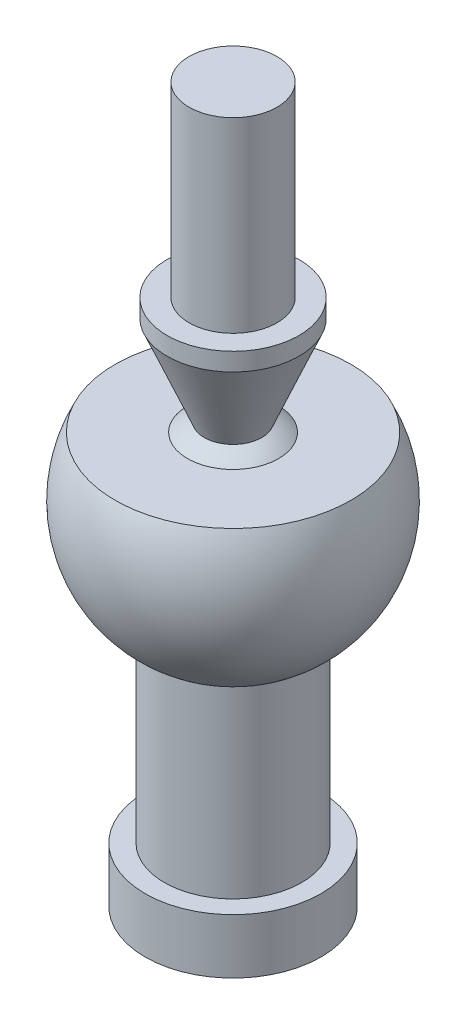
from build123d import *


with BuildPart() as part:
    # 草图1 → 旋转1 (revolve)
    with BuildSketch(Plane.XY):
        with BuildLine():
            Line((0, 12.038127602), (4, 9.728726525))
            Line((4, 9.728726525), (4, 0))
            Line((4, 0), (8, 0))
            Line((8, 0), (8, 5))
            Line((8, 5), (6.25, 5))
            Line((6.25, 5), (6.25, 21.756099376))
            ThreePointArc((6.25, 21.756099376), (11.534904039, 28.691527723), (10.729508749, 37.373792144))
            Line((10.729508749, 37.373792144), (4.14914812, 37.373792144))
            ThreePointArc((4.14914812, 37.373792144), (3.412230956, 37.869391112), (2.616929575, 38.264563171))
            Line((2.616929575, 38.264563171), (6, 46.363160318))
            Line((6, 46.363160318), (6, 48))
            Line((6, 48), (4, 48))
            Line((4, 48), (4, 65))
            Line((4, 65), (0, 65))
            Line((0, 65), (0, 12.038127602))
        make_face()
    revolve(axis=Axis((0, 0.112242194, 0), (0, 1, 0)))


solid = part.part
